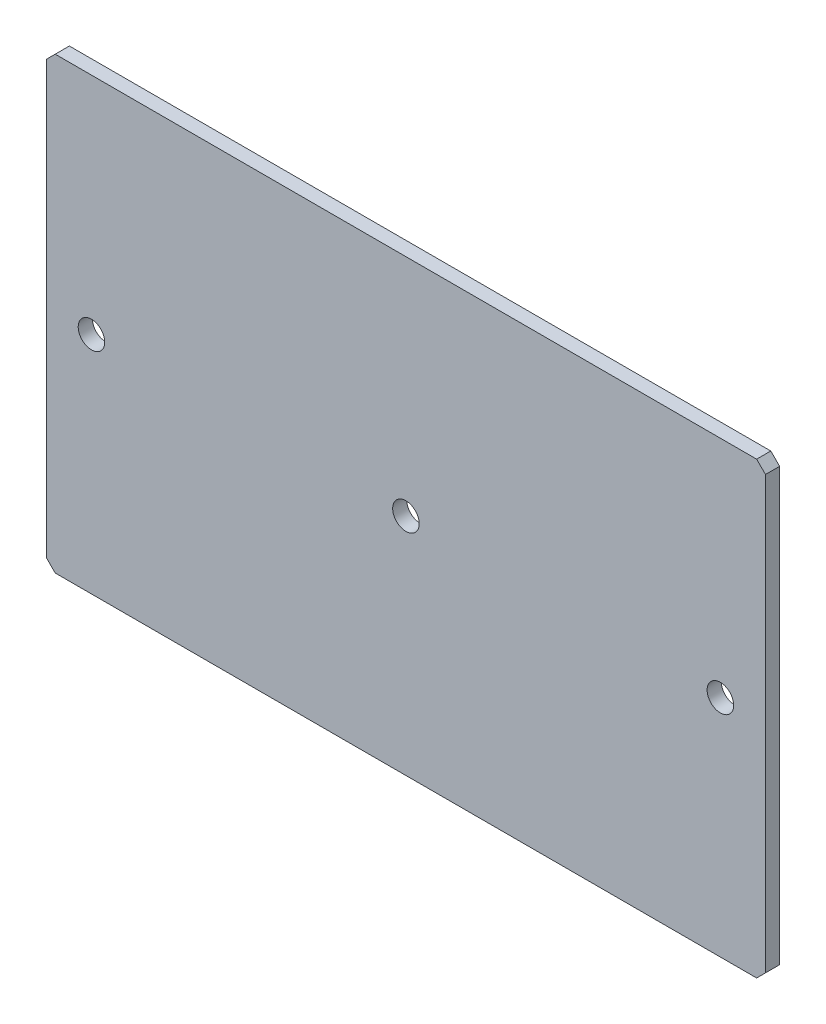
from build123d import *

# Parameters (mm, degrees)
SKETCH1_W           = 81.3
SKETCH1_H           = 50.8
SKETCH1_R           = 1.5
BOSS_EXTRUDE1_DEPTH = 1.6
CHAMFER1_SIZE       = 1


with BuildPart() as part:
    # Sketch1 → Boss-Extrude1 (new body)
    with BuildSketch(Plane.XY):
        with Locations((40.65, 25.4)):
            Rectangle(SKETCH1_W, SKETCH1_H)
        with Locations((5.1, 25.4)):
            Circle(SKETCH1_R, mode=Mode.SUBTRACT)
        with Locations((40.65, 25.4)):
            Circle(SKETCH1_R, mode=Mode.SUBTRACT)
        with Locations((76.2, 25.4)):
            Circle(SKETCH1_R, mode=Mode.SUBTRACT)
    extrude(amount=BOSS_EXTRUDE1_DEPTH)

    # Chamfer1
    chamfer1_edges = [part.edges().sort_by_distance(p)[0] for p in [
        (0, 50.8, 0.8),
        (81.3, 50.8, 0.8),
        (81.3, 0, 0.8),
        (0, 0, 0.8),
    ]]
    chamfer(chamfer1_edges, length=CHAMFER1_SIZE)


solid = part.part
